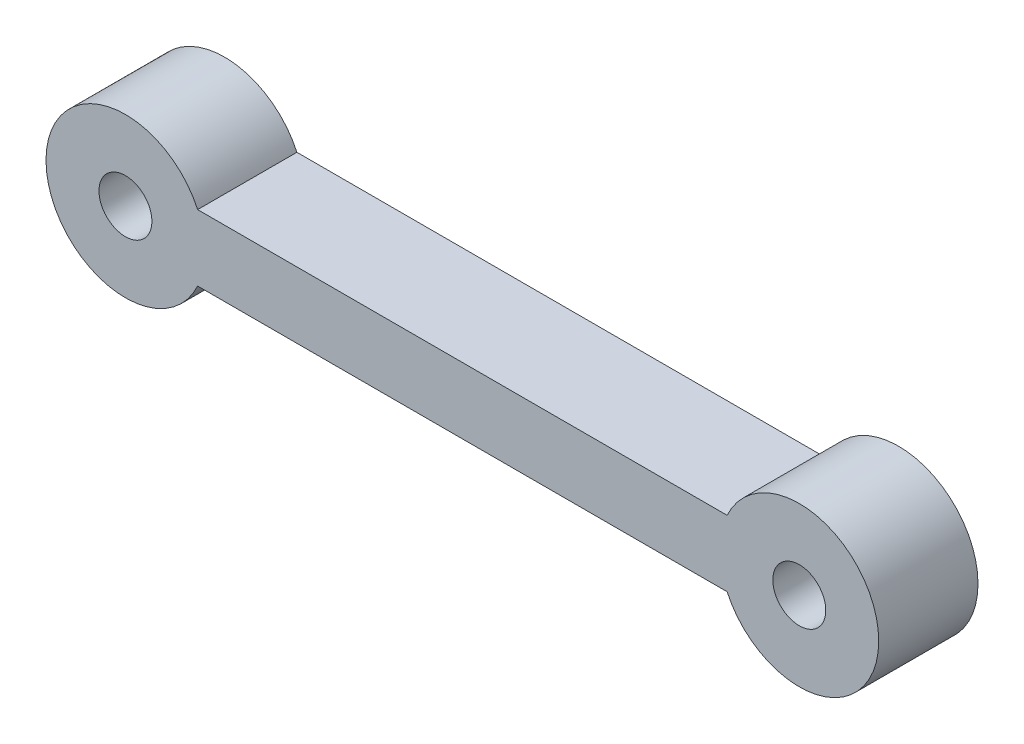
from build123d import *

# Parameters (mm, degrees)
SKETCH1_R           = 4
BOSS_EXTRUDE1_DEPTH = 15


with BuildPart() as part:
    # Sketch1 → Boss-Extrude1 (new body)
    with BuildSketch(Plane.XY):
        with BuildLine():
            Line((40, 0), (-40, 0))
            ThreePointArc((-40, 0), (-62.908712115, -5), (-40, -10))
            Line((-40, -10), (40, -10))
            ThreePointArc((40, -10), (62.908712115, -5), (40, 0))
        make_face()
        with Locations((-50.908712115, -5)):
            Circle(SKETCH1_R, mode=Mode.SUBTRACT)
        with Locations((50.908712115, -5)):
            Circle(SKETCH1_R, mode=Mode.SUBTRACT)
    extrude(amount=BOSS_EXTRUDE1_DEPTH)


solid = part.part
